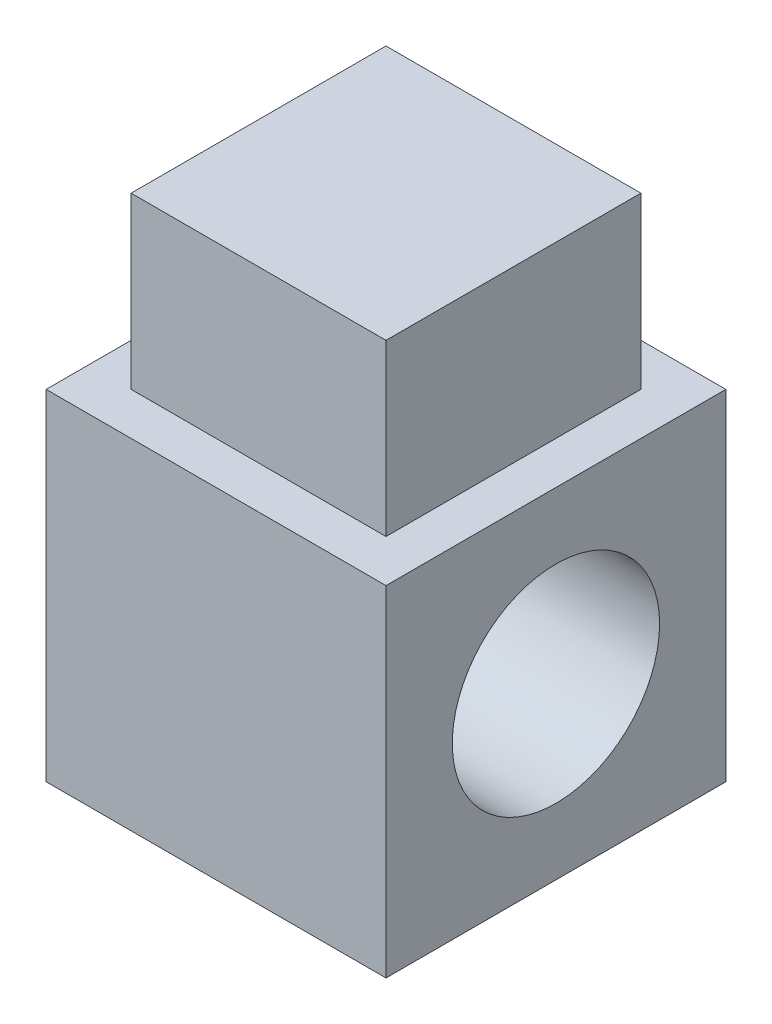
from build123d import *

# Parameters (mm, degrees)
SKETCH1_W           = 20
SKETCH1_H           = 20
SKETCH1_R           = 6.1
BOSS_EXTRUDE1_DEPTH = 10
SKETCH3_W           = 15
SKETCH3_H           = 15
BOSS_EXTRUDE2_DEPTH = 10


with BuildPart() as part:
    # Sketch1 → Boss-Extrude1 (new body, symmetric)
    with BuildSketch(Plane(origin=(0, 0, 0), x_dir=(0, 0, -1), z_dir=(1, 0, 0))):
        Rectangle(SKETCH1_W, SKETCH1_H)
        Circle(SKETCH1_R, mode=Mode.SUBTRACT)
    extrude(amount=BOSS_EXTRUDE1_DEPTH, both=True)

    # Sketch3 → Boss-Extrude2 (add)
    with BuildSketch(Plane(origin=(0, 10, 0), x_dir=(1, 0, 0), z_dir=(0, 1, 0))):
        Rectangle(SKETCH3_W, SKETCH3_H)
    extrude(amount=BOSS_EXTRUDE2_DEPTH)


solid = part.part
